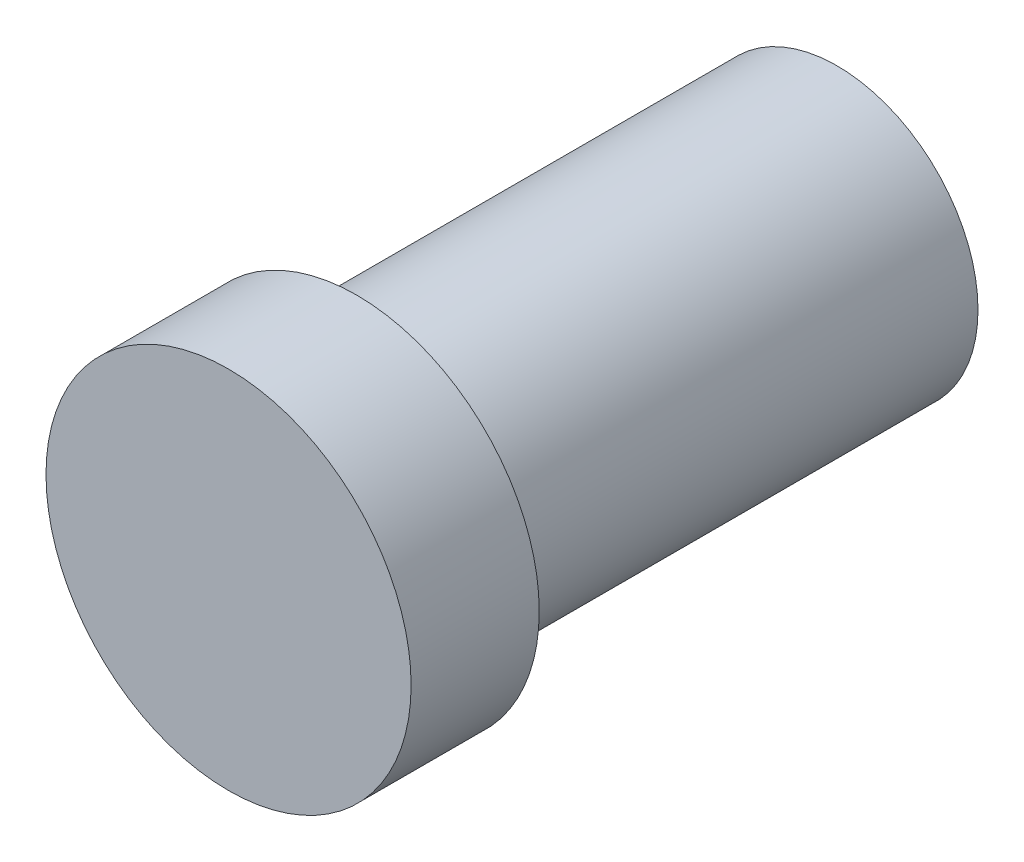
from build123d import *

# Parameters (mm, degrees)
SKETCH1_R           = 22
BOSS_EXTRUDE1_DEPTH = 75
SKETCH2_R           = 28.5
BOSS_EXTRUDE2_DEPTH = 20


with BuildPart() as part:
    # Sketch1 → Boss-Extrude1 (new body)
    with BuildSketch(Plane.XY):
        Circle(SKETCH1_R)
    extrude(amount=BOSS_EXTRUDE1_DEPTH)

    # Sketch2 → Boss-Extrude2 (add)
    with BuildSketch(Plane.XY.offset(75)):
        Circle(SKETCH2_R)
    extrude(amount=BOSS_EXTRUDE2_DEPTH)


solid = part.part
